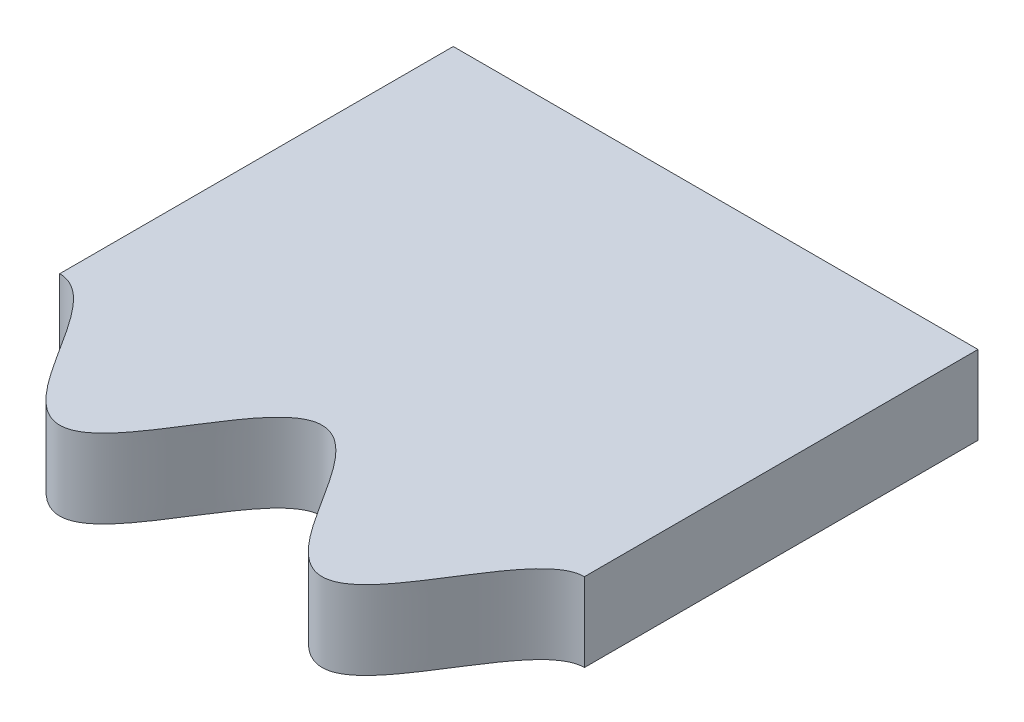
from build123d import *

# Parameters (mm, degrees)
SKETCH1_W               = 20
SKETCH1_H               = 20
BOSS_EXTRUDE1_DEPTH     = 3
CUT_EXTRUDE1_DEPTH      = 1
CUT_EXTRUDE1_DEPTH_BACK = 4


with BuildPart() as part:
    # Sketch1 → Boss-Extrude1 (new body)
    with BuildSketch(Plane(origin=(0, 0, 0), x_dir=(1, 0, 0), z_dir=(0, 1, 0))):
        Rectangle(SKETCH1_W, SKETCH1_H)
    extrude(amount=BOSS_EXTRUDE1_DEPTH)

    # Sketch2 → Cut-Extrude1 (cut, two sides)
    with BuildSketch(Plane(origin=(0, 3, 0), x_dir=(1, 0, 0), z_dir=(0, 1, 0))) as cut_extrude1_sk:
        with BuildLine():
            Line((10, -5), (10, -10))
            Line((10, -10), (-10, -10))
            Line((-10, -10), (-10, -5))
            add(Edge.make_bspline(
                [(-10, -5), (-9.990820014, -5), (-9.972446358, -5.000312583), (-9.939387471, -5.001719207), (-9.891969519, -5.005454846), (-9.835922238, -5.012412312), (-9.773033767, -5.024336094), (-9.698898541, -5.043219482), (-9.616042774, -5.071043877), (-9.515396925, -5.112824909), (-9.387330606, -5.178878831), (-9.23713056, -5.27635471), (-9.069968341, -5.409823327), (-8.904575648, -5.56508434), (-8.748961229, -5.730063259), (-8.601307785, -5.902136841), (-8.460077009, -6.079495517), (-8.324040002, -6.260844972), (-8.182655276, -6.458534299), (-8.035907031, -6.672418147), (-7.883481419, -6.902191288), (-7.724773455, -7.147377745), (-7.528350495, -7.455132252), (-7.293570647, -7.825001596), (-7.034646201, -8.226061179), (-6.743001489, -8.652533353), (-6.452756272, -9.038649676), (-6.159779288, -9.379451937), (-5.85167298, -9.669361598), (-5.520999117, -9.889512746), (-5.1671847, -10.010779605), (-4.816698271, -10.008204715), (-4.463198002, -9.88148029), (-4.132459412, -9.656303518), (-3.825186178, -9.363374601), (-3.53356605, -9.021407523), (-3.244609582, -8.635018563), (-2.954198132, -8.209090349), (-2.656866985, -7.747954266), (-2.345814717, -7.256271996), (-2.048553648, -6.795091334), (-1.758278976, -6.369070745), (-1.469541055, -5.982521438), (-1.178223955, -5.64030017), (-0.871397136, -5.346926797), (-0.541242947, -5.120949541), (-0.188339321, -4.992783545), (0.16212755, -4.988339301), (0.516516059, -5.108123798), (0.8477895, -5.327441362), (1.156337611, -5.616901018), (1.449649401, -5.957422311), (1.74008086, -6.343405241), (2.031929598, -6.769728753), (2.409645941, -7.354878505), (2.78090923, -7.94523233), (3.145749907, -8.501293993), (3.523293189, -9.008647271), (3.816859253, -9.354615385), (4.126025436, -9.651259116), (4.458963509, -9.879556068), (4.814535153, -10.008097061), (5.166519062, -10.011015315), (5.520996053, -9.889508756), (5.851675295, -9.66936442), (6.159777431, -9.379449939), (6.452757598, -9.03865066), (6.743000269, -8.652533063), (7.034647701, -8.226060806), (7.33317531, -7.763653858), (7.606423384, -7.331721448), (7.843119223, -6.963037632), (8.035904931, -6.672419587), (8.182657184, -6.458533403), (8.324037842, -6.260845485), (8.46008018, -6.079495251), (8.601302819, -5.902136908), (8.748969193, -5.730063373), (8.904563093, -5.565084029), (9.069986411, -5.409823833), (9.237102577, -5.276353888), (9.405693689, -5.166993054), (9.554516523, -5.093477505), (9.677662689, -5.048613087), (9.773048533, -5.024336542), (9.835921683, -5.012412295), (9.891968482, -5.005454815), (9.939387047, -5.001719194), (9.972446314, -5.000312581), (9.990820016, -5), (10, -5)],
                knots=[0.078815497, 0.078815497, 0.078815497, 0.078815497, 0.078815497, 0.080069856, 0.081324215, 0.082578574, 0.083832933, 0.086341651, 0.088850368, 0.091359086, 0.093867804, 0.09888524, 0.105408028, 0.111930817, 0.118453605, 0.124976394, 0.131499182, 0.138021971, 0.144544759, 0.151067548, 0.159472006, 0.167876463, 0.176280921, 0.184685379, 0.201494294, 0.21830321, 0.231223727, 0.244144245, 0.257064762, 0.26998528, 0.279768525, 0.289551769, 0.299506241, 0.309460713, 0.32238219, 0.335303668, 0.348225145, 0.361146623, 0.377889241, 0.394631859, 0.411374477, 0.428117095, 0.441038583, 0.453960071, 0.466881559, 0.479803047, 0.489757501, 0.499711955, 0.509495208, 0.519278461, 0.532198992, 0.545119522, 0.558040052, 0.570960582, 0.587769476, 0.604578369, 0.638196155, 0.651241751, 0.664287347, 0.677332943, 0.690378539, 0.700413385, 0.710448231, 0.720231475, 0.73001472, 0.742935238, 0.755855755, 0.768776273, 0.78169679, 0.798505706, 0.815314621, 0.832123537, 0.840527994, 0.848932452, 0.855455241, 0.861978029, 0.868500818, 0.875023606, 0.881546395, 0.888069183, 0.894591972, 0.90111476, 0.906132196, 0.911149632, 0.913658349, 0.916167067, 0.917421426, 0.918675785, 0.919930144, 0.921184503, 0.921184503, 0.921184503, 0.921184503, 0.921184503], degree=4))
        make_face()
    extrude(amount=CUT_EXTRUDE1_DEPTH, mode=Mode.SUBTRACT)
    extrude(cut_extrude1_sk.sketch, amount=-CUT_EXTRUDE1_DEPTH_BACK, mode=Mode.SUBTRACT)


solid = part.part
